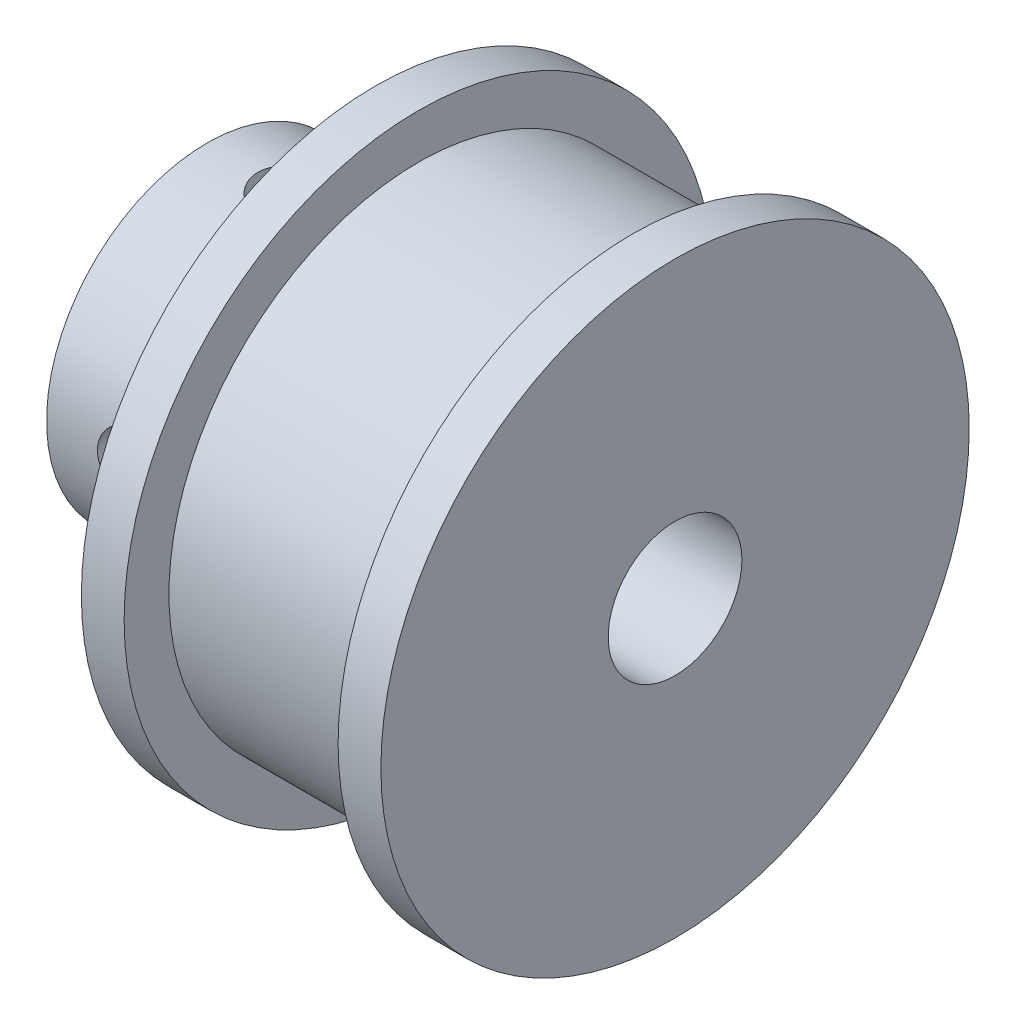
from build123d import *

# Parameters (mm, degrees)
SKETCH2_W = 1.25
SKETCH2_H = 11
SKETCH4_W = 1.25
SKETCH4_H = 11


with BuildPart() as part:
    # Sketch1 → Revolve1 (revolve)
    with BuildSketch(Plane.XY):
        Polygon((0, 2.5), (0, 6), (6.3, 6), (6.3, 11), (7.9, 11), (7.9, 9.325), (15.9, 9.325), (15.9, 11), (17.5, 11), (17.5, 2.5), align=None)
    revolve(axis=Axis((0, 0, 0), (-1, 0, 0)))

    # Sketch2 → M3x0.5 Tapped Hole1 (revolve, cut)
    with BuildSketch(Plane(origin=(3.15, 0, 0), x_dir=(0, 0, -1), z_dir=(1, 0, 0))):
        with Locations((0.625, 5.5)):
            Rectangle(SKETCH2_W, SKETCH2_H)
    revolve(axis=Axis((3.15, -6.35, 0), (0, 1, 0)), mode=Mode.SUBTRACT)

    # Sketch4 → M3x0.5 Tapped Hole2 (revolve, cut)
    with BuildSketch(Plane.YZ.offset(3.15)):
        with Locations((0.625, 5.5)):
            Rectangle(SKETCH4_W, SKETCH4_H)
    revolve(axis=Axis((3.15, 0, -6.35), (0, 0, 1)), mode=Mode.SUBTRACT)


solid = part.part
